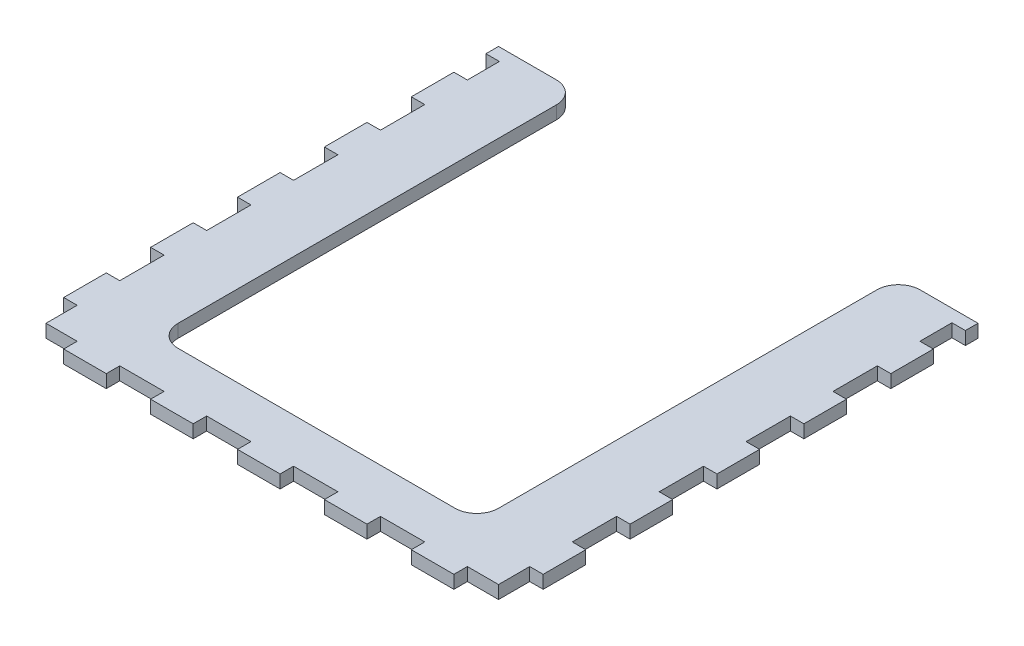
from build123d import *

# Parameters (mm, degrees)
BOSS_EXTRUDE1_DEPTH = 3
SKETCH3_W           = 3.2
SKETCH3_H           = 10.2
SKETCH3_W_2         = 10.2
SKETCH3_H_2         = 3.2
SKETCH3_H_3         = 7.372217102
CUT_EXTRUDE1_DEPTH  = 4


with BuildPart() as part:
    # Sketch1 → Boss-Extrude1 (new body)
    with BuildSketch(Plane(origin=(0, 0, 0), x_dir=(1, 0, 0), z_dir=(0, 1, 0))):
        with BuildLine():
            Line((-55.172217102, 43.501443346), (-41.872217102, 43.501443346))
            ThreePointArc((-41.872217102, 43.501443346), (-38.336683196, 42.036977252), (-36.872217102, 38.501443346))
            Line((-36.872217102, 38.501443346), (-36.872217102, -48.542990858))
            ThreePointArc((-36.872217102, -48.542990858), (-35.407751008, -52.078524764), (-31.872217102, -53.542990858))
            Line((-31.872217102, -53.542990858), (31.872217102, -53.542990858))
            ThreePointArc((31.872217102, -53.542990858), (35.407751008, -52.078524764), (36.872217102, -48.542990858))
            Line((36.872217102, -48.542990858), (36.872217102, 38.501443346))
            ThreePointArc((36.872217102, 38.501443346), (38.336683196, 42.036977252), (41.872217102, 43.501443346))
            Line((41.872217102, 43.501443346), (55.172217102, 43.501443346))
            Line((55.172217102, 43.501443346), (55.172217102, -66.842990858))
            Line((55.172217102, -66.842990858), (-55.172217102, -66.842990858))
            Line((-55.172217102, -66.842990858), (-55.172217102, 43.501443346))
        make_face()
    extrude(amount=-BOSS_EXTRUDE1_DEPTH)

    # Sketch3 → Cut-Extrude1 (cut, through all)
    with BuildSketch(Plane(origin=(0, 0, 0), x_dir=(1, 0, 0), z_dir=(0, 1, 0))):
        with Locations((53.672217102, -41.670773756)):
            Rectangle(SKETCH3_W, SKETCH3_H)
        Polygon((52.072217102, -56.570773756), (55.272217102, -56.570773756), (55.272217102, -66.942990858), (44.9, -66.942990858), (44.9, -63.742990858), (52.072217102, -63.742990858), align=None)
        with Locations((30, -65.342990858)):
            Rectangle(SKETCH3_W_2, SKETCH3_H_2)
        with Locations((53.672217102, 18.329226244)):
            Rectangle(SKETCH3_W, SKETCH3_H)
        with Locations((53.672217102, -1.670773756)):
            Rectangle(SKETCH3_W, SKETCH3_H)
        with Locations((53.672217102, 36.915334795)):
            Rectangle(SKETCH3_W, SKETCH3_H_3)
        with Locations((10, -65.342990858)):
            Rectangle(SKETCH3_W_2, SKETCH3_H_2)
        with Locations((53.672217102, -21.670773756)):
            Rectangle(SKETCH3_W, SKETCH3_H)
        with Locations((-53.672217102, 36.915334795)):
            Rectangle(SKETCH3_W, SKETCH3_H_3)
        with Locations((-10, -65.342990858)):
            Rectangle(SKETCH3_W_2, SKETCH3_H_2)
        with Locations((-53.672217102, -1.670773756)):
            Rectangle(SKETCH3_W, SKETCH3_H)
        with Locations((-53.672217102, 18.329226244)):
            Rectangle(SKETCH3_W, SKETCH3_H)
        with Locations((-30, -65.342990858)):
            Rectangle(SKETCH3_W_2, SKETCH3_H_2)
        Polygon((-44.9, -66.942990858), (-55.272217102, -66.942990858), (-55.272217102, -56.570773756), (-52.072217102, -56.570773756), (-52.072217102, -63.742990858), (-44.9, -63.742990858), align=None)
        with Locations((-53.672217102, -41.670773756)):
            Rectangle(SKETCH3_W, SKETCH3_H)
        with Locations((-53.672217102, -21.670773756)):
            Rectangle(SKETCH3_W, SKETCH3_H)
    extrude(amount=-CUT_EXTRUDE1_DEPTH, mode=Mode.SUBTRACT)


solid = part.part
